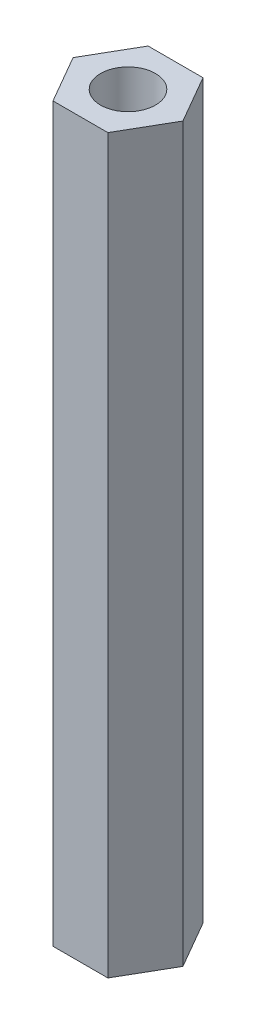
from build123d import *

# Parameters (mm, degrees)
SKETCH_1_R      = 1.5
EXTRUDE_1_DEPTH = 40


with BuildPart() as part:
    # 草图1 → 凸台-拉伸1 (new body)
    with BuildSketch(Plane(origin=(0, 0, 0), x_dir=(1, 0, 0), z_dir=(0, 1, 0))):
        Polygon((3, 0), (1.5, 2.598076211), (-1.5, 2.598076211), (-3, 0), (-1.5, -2.598076211), (1.5, -2.598076211), align=None)
        Circle(SKETCH_1_R, mode=Mode.SUBTRACT)
    extrude(amount=EXTRUDE_1_DEPTH)


solid = part.part
